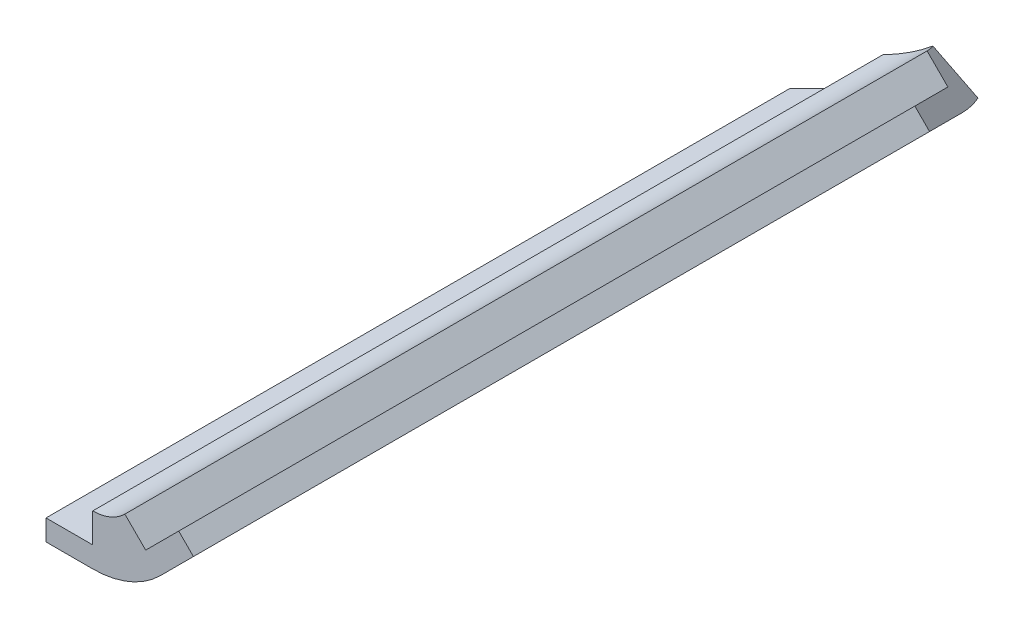
from build123d import *

# Parameters (mm, degrees)
SKETCH7_W               = 4.7625
SKETCH7_H               = 2.12122512
BOSS_EXTRUDE2_DEPTH     = 130.175
BOSS_EXTRUDE3_DEPTH     = 130.175
BOSS_EXTRUDE4_DEPTH     = 130.175
CUT_EXTRUDE1_DEPTH      = 1
CUT_EXTRUDE1_DEPTH_BACK = 118.807865064
SKETCH18_W              = 254
SKETCH18_H              = 254
CUT_EXTRUDE2_DEPTH      = 80.261506


with BuildPart() as part:
    # Sketch7 → Boss-Extrude2 (new body, symmetric)
    with BuildSketch(Plane.XY):
        with Locations((-4.92125, -2.560612608)):
            Rectangle(SKETCH7_W, SKETCH7_H)
    extrude(amount=BOSS_EXTRUDE2_DEPTH, both=True)



with BuildPart() as body_2:
    # Sketch8 → Boss-Extrude3 (new body, symmetric)
    with BuildSketch(Plane.XY):
        Polygon((2.85671143, 0.735391018), (6.224307475, 4.102987064), (7.724240142, 2.603054397), (4.356644097, -0.764541648), align=None)
    extrude(amount=BOSS_EXTRUDE3_DEPTH, both=True)


with BuildPart() as part_1:
    add(part.part)

    add(body_2.part)  # Boss-Extrude4 merges body 2
    # Sketch11 → Boss-Extrude4 (add, symmetric)
    with BuildSketch(Plane.XY):
        with BuildLine():
            Line((-2.54, -1.500000048), (-7.3025, -1.500000048))
            Line((-7.3025, -1.500000048), (-7.3025, -3.621225168))
            Line((-7.3025, -3.621225168), (-2.54, -3.621225168))
            ThreePointArc((-2.54, -3.621225168), (1.192436889, -2.87879731), (4.356644097, -0.764541648))
            Line((4.356644097, -0.764541648), (7.724240142, 2.603054397))
            Line((7.724240142, 2.603054397), (6.224307475, 4.102987064))
            Line((6.224307475, 4.102987064), (2.85671143, 0.735391018))
            Line((2.85671143, 0.735391018), (0.735391018, 2.85671143))
            ThreePointArc((0.735391018, 2.85671143), (-0.767371154, 1.852597848), (-2.54, 1.500000048))
            Line((-2.54, 1.500000048), (-2.54, -1.500000048))
        make_face()
    extrude(amount=BOSS_EXTRUDE4_DEPTH, both=True)

    # Sketch17 → Cut-Extrude1 (cut, two sides)
    with BuildSketch(Plane(origin=(47.098102576, -113.704878, 0), x_dir=(-1, 0, 0), z_dir=(0, -1, 0))) as cut_extrude1_sk:
        Polygon((-898.025612107, 898.025612107), (898.025612107, -898.025612107), (2694.076836321, 898.025612107), (898.025612107, 2694.076836321), align=None)
    extrude(amount=CUT_EXTRUDE1_DEPTH, mode=Mode.SUBTRACT)
    extrude(cut_extrude1_sk.sketch, amount=-CUT_EXTRUDE1_DEPTH_BACK, mode=Mode.SUBTRACT)

    # Sketch18 → Cut-Extrude2 (cut)
    with BuildSketch(Plane(origin=(47.098102576, 47.098102576, 0), x_dir=(0.816496581, -0.40824829, 0.40824829), z_dir=(0.577350269, 0.577350269, -0.577350269))):
        Rectangle(SKETCH18_W, SKETCH18_H)
    extrude(amount=-CUT_EXTRUDE2_DEPTH, mode=Mode.SUBTRACT)


solid = part_1.part
